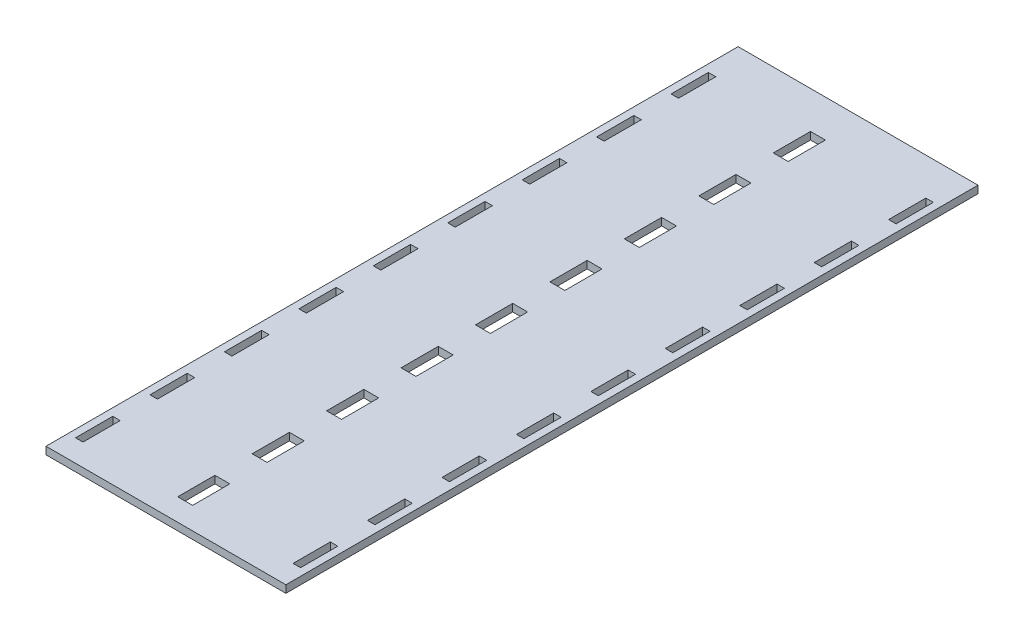
from build123d import *

# Parameters (mm, degrees)
SKETCH_1_W      = 128.9
SKETCH_1_H      = 371.87
SKETCH_1_W_2    = 8
SKETCH_1_H_2    = 20
SKETCH_1_W_3    = 4
EXTRUDE_1_DEPTH = 4


with BuildPart() as part:
    # Эскиз1 → Бобышка-Вытянуть1 (new body)
    with BuildSketch(Plane(origin=(0, 0, 0), x_dir=(1, 0, 0), z_dir=(0, 1, 0))):
        with Locations((1.55, -185.935)):
            Rectangle(SKETCH_1_W, SKETCH_1_H)
        with Locations((0, -70)):
            Rectangle(SKETCH_1_W_2, SKETCH_1_H_2, mode=Mode.SUBTRACT)
        with Locations((0, -30)):
            Rectangle(SKETCH_1_W_2, SKETCH_1_H_2, mode=Mode.SUBTRACT)
        with Locations((0, -110)):
            Rectangle(SKETCH_1_W_2, SKETCH_1_H_2, mode=Mode.SUBTRACT)
        with Locations((0, -150)):
            Rectangle(SKETCH_1_W_2, SKETCH_1_H_2, mode=Mode.SUBTRACT)
        with Locations((0, -190)):
            Rectangle(SKETCH_1_W_2, SKETCH_1_H_2, mode=Mode.SUBTRACT)
        with Locations((0, -230)):
            Rectangle(SKETCH_1_W_2, SKETCH_1_H_2, mode=Mode.SUBTRACT)
        with Locations((0, -270)):
            Rectangle(SKETCH_1_W_2, SKETCH_1_H_2, mode=Mode.SUBTRACT)
        with Locations((0, -310)):
            Rectangle(SKETCH_1_W_2, SKETCH_1_H_2, mode=Mode.SUBTRACT)
        with Locations((0, -350)):
            Rectangle(SKETCH_1_W_2, SKETCH_1_H_2, mode=Mode.SUBTRACT)
        with Locations((-56.9, -30)):
            Rectangle(SKETCH_1_W_3, SKETCH_1_H_2, mode=Mode.SUBTRACT)
        with Locations((-56.9, -70)):
            Rectangle(SKETCH_1_W_3, SKETCH_1_H_2, mode=Mode.SUBTRACT)
        with Locations((-56.9, -110)):
            Rectangle(SKETCH_1_W_3, SKETCH_1_H_2, mode=Mode.SUBTRACT)
        with Locations((-56.9, -150)):
            Rectangle(SKETCH_1_W_3, SKETCH_1_H_2, mode=Mode.SUBTRACT)
        with Locations((-56.9, -190)):
            Rectangle(SKETCH_1_W_3, SKETCH_1_H_2, mode=Mode.SUBTRACT)
        with Locations((-56.9, -230)):
            Rectangle(SKETCH_1_W_3, SKETCH_1_H_2, mode=Mode.SUBTRACT)
        with Locations((-56.9, -270)):
            Rectangle(SKETCH_1_W_3, SKETCH_1_H_2, mode=Mode.SUBTRACT)
        with Locations((-56.9, -310)):
            Rectangle(SKETCH_1_W_3, SKETCH_1_H_2, mode=Mode.SUBTRACT)
        with Locations((-56.9, -350)):
            Rectangle(SKETCH_1_W_3, SKETCH_1_H_2, mode=Mode.SUBTRACT)
        with Locations((60, -70)):
            Rectangle(SKETCH_1_W_3, SKETCH_1_H_2, mode=Mode.SUBTRACT)
        with Locations((60, -30)):
            Rectangle(SKETCH_1_W_3, SKETCH_1_H_2, mode=Mode.SUBTRACT)
        with Locations((60, -110)):
            Rectangle(SKETCH_1_W_3, SKETCH_1_H_2, mode=Mode.SUBTRACT)
        with Locations((60, -150)):
            Rectangle(SKETCH_1_W_3, SKETCH_1_H_2, mode=Mode.SUBTRACT)
        with Locations((60, -190)):
            Rectangle(SKETCH_1_W_3, SKETCH_1_H_2, mode=Mode.SUBTRACT)
        with Locations((60, -230)):
            Rectangle(SKETCH_1_W_3, SKETCH_1_H_2, mode=Mode.SUBTRACT)
        with Locations((60, -270)):
            Rectangle(SKETCH_1_W_3, SKETCH_1_H_2, mode=Mode.SUBTRACT)
        with Locations((60, -310)):
            Rectangle(SKETCH_1_W_3, SKETCH_1_H_2, mode=Mode.SUBTRACT)
        with Locations((60, -350)):
            Rectangle(SKETCH_1_W_3, SKETCH_1_H_2, mode=Mode.SUBTRACT)
    extrude(amount=EXTRUDE_1_DEPTH)


solid = part.part
